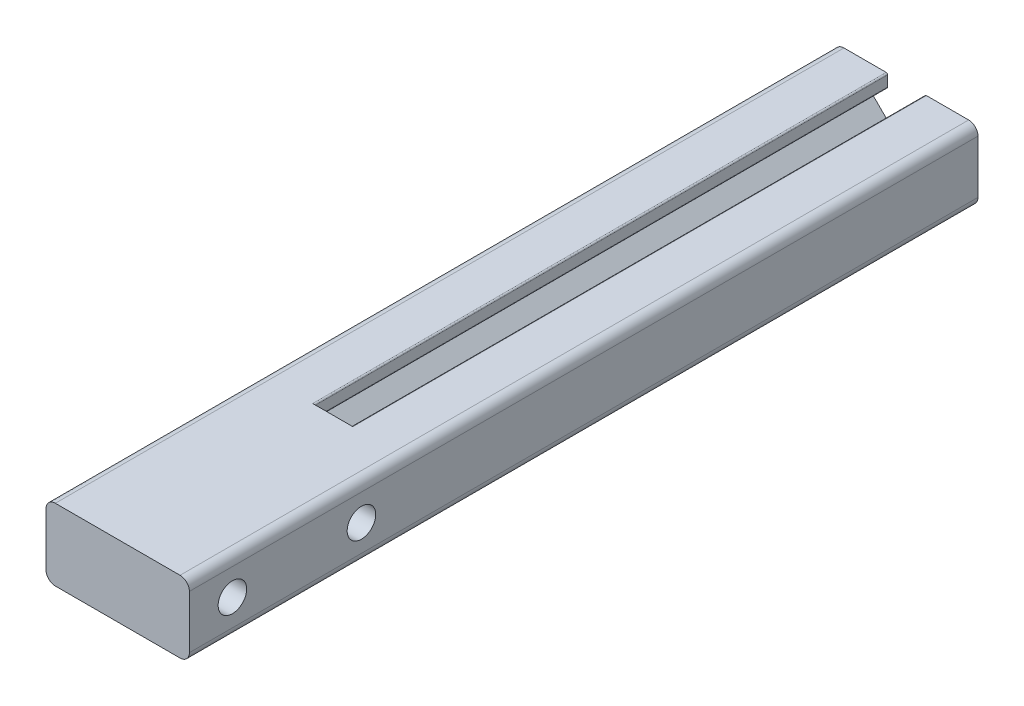
from build123d import *

# Parameters (mm, degrees)
SKETCH3_R                  = 3.2385
BOSS_EXTRUDE1_DEPTH        = 50.8
FILLET1_R                  = 0.254
BOSS_EXTRUDE2_DEPTH        = 38.1
F_8_0_199_DIAMETER_HOLE1_D = 5.0546
LPATTERN1_COUNT            = 2
LPATTERN1_PITCH            = 22.86


with BuildPart() as part:
    # Sketch3 → Boss-Extrude1 (new body, symmetric)
    with BuildSketch(Plane.XY):
        with BuildLine():
            Line((-11.049, 12.7), (-3.302, 12.7))
            Line((-3.302, 12.7), (-3.302, 10.328863887))
            Line((-3.302, 10.328863887), (-6.985, 10.328863887))
            ThreePointArc((-6.985, 10.328863887), (-7.454330803, 10.01526707), (-7.344210245, 9.461653642))
            Line((-7.344210245, 9.461653642), (-3.452505379, 5.569948776))
            ThreePointArc((-3.452505379, 5.569948776), (-2.628470073, 5.019345987), (-1.656454155, 4.826))
            Line((-1.656454155, 4.826), (1.656454155, 4.826))
            ThreePointArc((1.656454155, 4.826), (2.628470073, 5.019345987), (3.452505379, 5.569948776))
            Line((3.452505379, 5.569948776), (7.344210245, 9.461653642))
            ThreePointArc((7.344210245, 9.461653642), (7.454330803, 10.01526707), (6.985, 10.328863887))
            Line((6.985, 10.328863887), (3.302, 10.328863887))
            Line((3.302, 10.328863887), (3.302, 12.7))
            Line((3.302, 12.7), (11.049, 12.7))
            ThreePointArc((11.049, 12.7), (12.216433296, 12.216433296), (12.7, 11.049))
            Line((12.7, 11.049), (12.7, 1.651))
            ThreePointArc((12.7, 1.651), (12.216433296, 0.483566704), (11.049, 0))
            Line((11.049, 0), (-11.049, 0))
            ThreePointArc((-11.049, 0), (-12.216433296, 0.483566704), (-12.7, 1.651))
            Line((-12.7, 1.651), (-12.7, 11.049))
            ThreePointArc((-12.7, 11.049), (-12.216433296, 12.216433296), (-11.049, 12.7))
        make_face()
        with Locations((8.509, 4.064)):
            Circle(SKETCH3_R, mode=Mode.SUBTRACT)
        with Locations((-8.509, 4.064)):
            Circle(SKETCH3_R, mode=Mode.SUBTRACT)
    extrude(amount=BOSS_EXTRUDE1_DEPTH, both=True)

    # Fillet1
    fillet1_edges = [part.edges().sort_by_distance(p)[0] for p in [
        (-3.302, 12.7, 0),
        (-3.302, 10.328863887, 0),
        (3.302, 10.328863887, 0),
        (3.302, 12.7, 0),
    ]]
    fillet(fillet1_edges, radius=FILLET1_R)

    # Sketch4 → Boss-Extrude2 (add)
    with BuildSketch(Plane(origin=(0, 0, 50.8), x_dir=(-1, 0, 0), z_dir=(0, 0, -1))):
        with BuildLine():
            Line((3.556, 12.7), (-11.049, 12.7))
            ThreePointArc((-11.049, 12.7), (-12.216433296, 12.216433296), (-12.7, 11.049))
            Line((-12.7, 11.049), (-12.7, 1.651))
            ThreePointArc((-12.7, 1.651), (-12.216433296, 0.483566704), (-11.049, 0))
            Line((-11.049, 0), (11.049, 0))
            ThreePointArc((11.049, 0), (12.216433296, 0.483566704), (12.7, 1.651))
            Line((12.7, 1.651), (12.7, 11.049))
            ThreePointArc((12.7, 11.049), (12.216433296, 12.216433296), (11.049, 12.7))
            Line((11.049, 12.7), (3.556, 12.7))
        make_face()
    extrude(amount=-BOSS_EXTRUDE2_DEPTH)

    # #8 (0.199) Diameter Hole1 (through all)
    with Locations(Plane(origin=(12.7, 0, 0), x_dir=(0, 0, -1), z_dir=(1, 0, 0))):
        with Locations((-81.28, 6.35)):
            f_8_0_199_diameter_hole1 = Hole(F_8_0_199_DIAMETER_HOLE1_D / 2)

    # LPattern1: #8 (0.199) Diameter Hole1 ×2
    with Locations(*[(0, 0, -i * LPATTERN1_PITCH) for i in range(1, LPATTERN1_COUNT)]):
        add(f_8_0_199_diameter_hole1, mode=Mode.SUBTRACT)


solid = part.part
